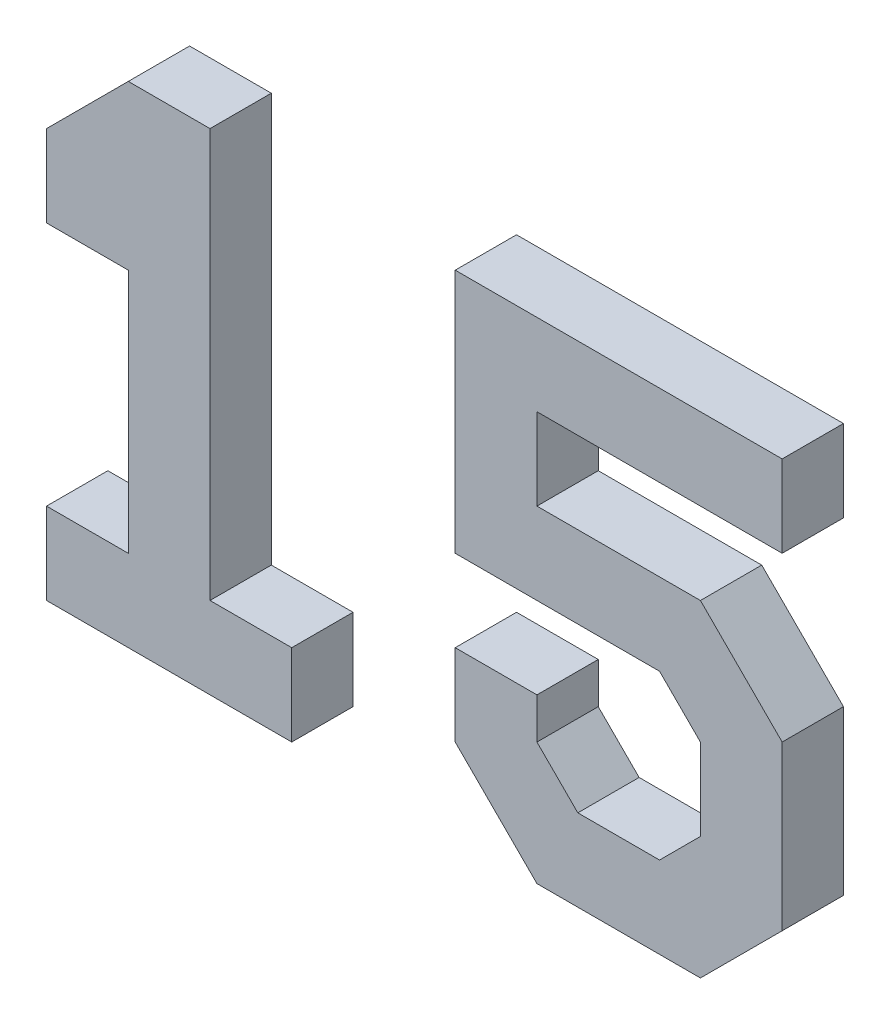
from build123d import *

# Parameters (mm, degrees)
EXTRUDE1_DEPTH   = 15
EXTRUDE1_2_DEPTH = 15


with BuildPart() as part:
    # Sketch1 → Extrude1 (new body)
    with BuildSketch(Plane.XY):
        Polygon((20, 120), (40, 120), (40, 20), (60, 20), (60, 0), (0, 0), (0, 20), (20, 20), (20, 80), (0, 80), (0, 100), align=None)
    extrude(amount=EXTRUDE1_DEPTH)


with BuildPart() as body_2:
    # Sketch1 → Extrude1 2 (new body)
    with BuildSketch(Plane.XY):
        Polygon((100, 120), (180, 120), (180, 100), (120, 100), (120, 80), (160, 80), (180, 60), (180, 20), (160, 0), (120, 0), (100, 20), (100, 40), (120, 40), (120, 30), (130, 20), (150, 20), (160, 30), (160, 50), (150, 60), (100, 60), align=None)
    extrude(amount=EXTRUDE1_2_DEPTH)


solid = Compound([part.part, body_2.part])
